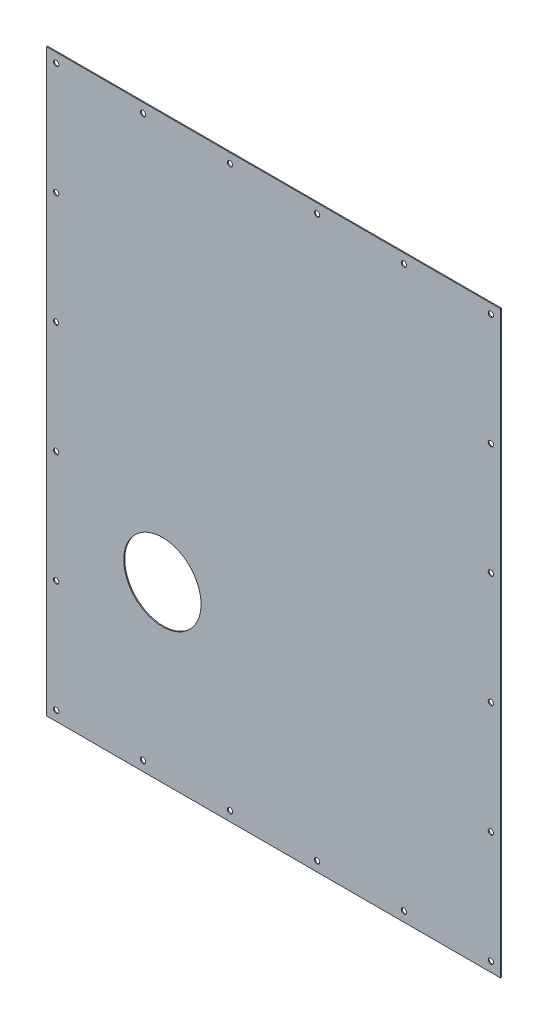
from build123d import *

# Parameters (mm, degrees)
SKETCH_1_W          = 470
SKETCH_1_H          = 600
EXTRUDE_1_DEPTH     = 1
HOLE_WIZARD_M5_1_D  = 5.5
SKETCH_4_R          = 40
CUT_EXTRUDE_1_DEPTH = 10


with BuildPart() as part:
    # 스케치1 → 보스-돌출1 (new body)
    with BuildSketch(Plane.XY):
        Rectangle(SKETCH_1_W, SKETCH_1_H)
    extrude(amount=EXTRUDE_1_DEPTH)

    # M5 여유 구멍1 (through all)
    with Locations(Plane(origin=(0, 0, 0), x_dir=(-1, 0, 0), z_dir=(0, 0, -1))):
        with Locations((-225, 290), (-135, 290), (-45, 290), (45, 290), (135, 290), (225, 290), (225, 174), (225, 58), (225, -58), (225, -174), (225, -290), (-225, 174), (-225, 58), (-225, -58), (-225, -174), (-225, -290), (-135, -290), (-45, -290), (45, -290), (135, -290)):
            Hole(HOLE_WIZARD_M5_1_D / 2)

    # 스케치4 → 컷-돌출1 (cut)
    with BuildSketch(Plane(origin=(0, 0, 0), x_dir=(-1, 0, 0), z_dir=(0, 0, -1))):
        with Locations((115, -120)):
            Circle(SKETCH_4_R)
    extrude(amount=-CUT_EXTRUDE_1_DEPTH, mode=Mode.SUBTRACT)


solid = part.part
